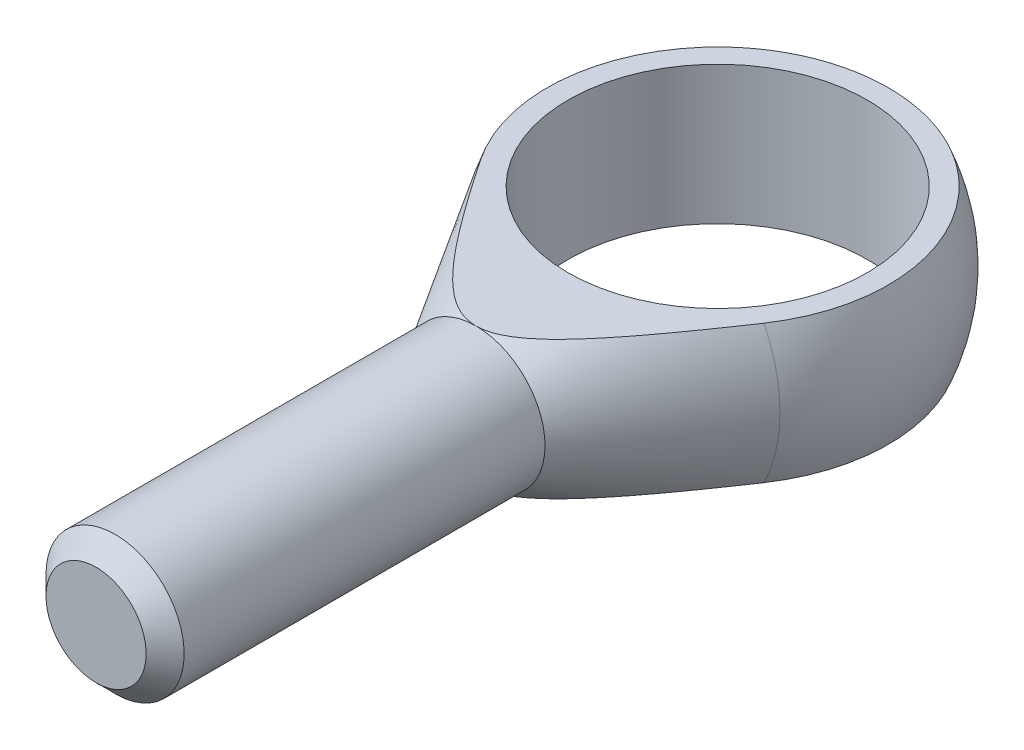
from build123d import *

# Parameters (mm, degrees)
SZKIC1_W                        = 6
SZKIC1_H                        = 33
WYTNIJ_WYCI_GNI_CIE1_DEPTH      = 17
WYTNIJ_WYCI_GNI_CIE1_DEPTH_BACK = 17
SZKIC3_R                        = 13
WYTNIJ_WYCI_GNI_CIE2_DEPTH      = 7
WYTNIJ_WYCI_GNI_CIE2_DEPTH_BACK = 7
SFAZOWANIE1_SIZE                = 1.65


with BuildPart() as part:
    # Szkic1 → Obrót1 (revolve)
    with BuildSketch(Plane(origin=(0, 0, 0), x_dir=(1, 0, 0), z_dir=(0, 1, 0))):
        with BuildLine():
            Line((0, 16), (0, -21))
            Line((0, -21), (6, -21))
            Line((6, -21), (13.691822011, -8.278527045))
            ThreePointArc((13.691822011, -8.278527045), (13.936578359, 7.859502761), (0, 16))
        make_face()
        with Locations((3, -37.5)):
            Rectangle(SZKIC1_W, SZKIC1_H)
    revolve(axis=Axis((0, 0, -26.043516498), (0, 0, 1)))

    # Szkic2 → Wytnij-wyciągnięcie1 (cut, two sides)
    with BuildSketch(Plane(origin=(0, 0, 0), x_dir=(0, 0, -1), z_dir=(1, 0, 0))) as wytnij_wyci_gni_cie1_sk:
        with BuildLine():
            Line((-21, 6), (14.832396974, 6))
            ThreePointArc((14.832396974, 6), (5.052656155, 15.181260349), (-8.278527045, 13.691822011))
            Line((-8.278527045, 13.691822011), (-21, 6))
        make_face()
        with BuildLine():
            Line((-21, -6), (14.832396974, -6))
            ThreePointArc((14.832396974, -6), (5.052656155, -15.181260349), (-8.278527045, -13.691822011))
            Line((-8.278527045, -13.691822011), (-21, -6))
        make_face()
    extrude(amount=WYTNIJ_WYCI_GNI_CIE1_DEPTH, mode=Mode.SUBTRACT)
    extrude(wytnij_wyci_gni_cie1_sk.sketch, amount=-WYTNIJ_WYCI_GNI_CIE1_DEPTH_BACK, mode=Mode.SUBTRACT)

    # Szkic3 → Wytnij-wyciągnięcie2 (cut, two sides)
    with BuildSketch(Plane(origin=(0, 0, 0), x_dir=(1, 0, 0), z_dir=(0, 1, 0))) as wytnij_wyci_gni_cie2_sk:
        Circle(SZKIC3_R)
    extrude(amount=WYTNIJ_WYCI_GNI_CIE2_DEPTH, mode=Mode.SUBTRACT)
    extrude(wytnij_wyci_gni_cie2_sk.sketch, amount=-WYTNIJ_WYCI_GNI_CIE2_DEPTH_BACK, mode=Mode.SUBTRACT)

    # Sfazowanie1
    sfazowanie1_edges = [part.edges().sort_by_distance(p)[0] for p in [
        (-6, 0, 54),
    ]]
    chamfer(sfazowanie1_edges, length=SFAZOWANIE1_SIZE)


solid = part.part
